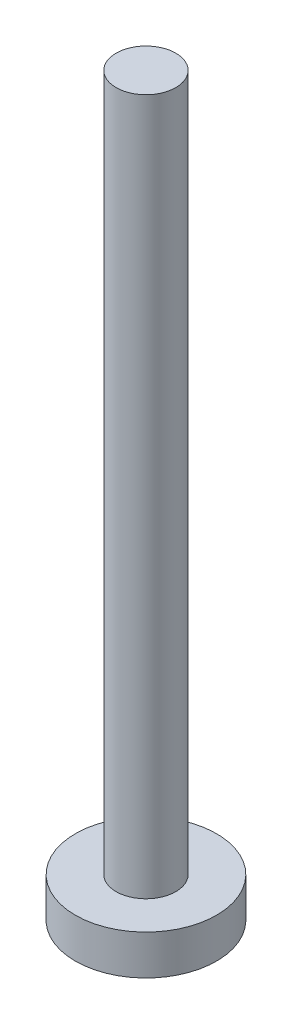
from build123d import *

# Parameters (mm, degrees)
SKETCH_1_R      = 3.55
EXTRUDE_1_DEPTH = 2
SKETCH_2_R      = 1.5
EXTRUDE_2_DEPTH = 35


with BuildPart() as part:
    # 草图1 → 凸台-拉伸1 (new body)
    with BuildSketch(Plane(origin=(0, 0, 0), x_dir=(1, 0, 0), z_dir=(0, 1, 0))):
        Circle(SKETCH_1_R)
    extrude(amount=EXTRUDE_1_DEPTH)

    # 草图2 → 凸台-拉伸2 (add)
    with BuildSketch(Plane(origin=(0, 2, 0), x_dir=(1, 0, 0), z_dir=(0, 1, 0))):
        Circle(SKETCH_2_R)
    extrude(amount=EXTRUDE_2_DEPTH)


solid = part.part
